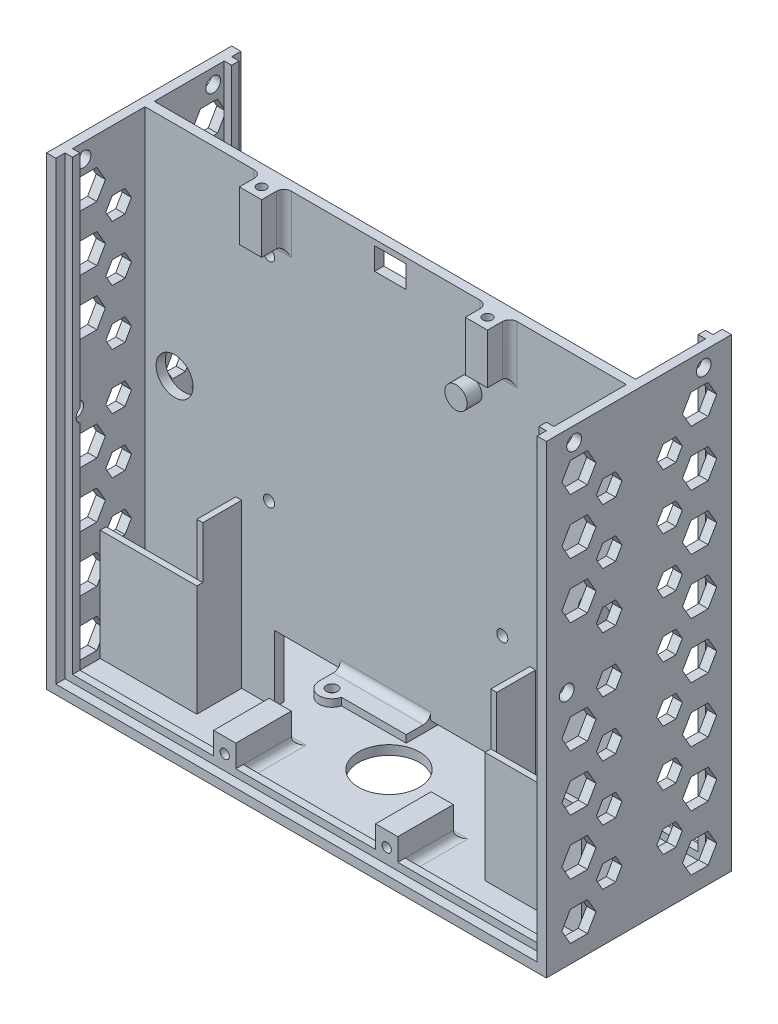
from build123d import *

# Parameters (mm, degrees)
SKETCH1_W                = 130
SKETCH1_H                = 123
SKETCH1_R                = 1.5
SKETCH1_R_2              = 5
SKETCH1_W_2              = 8.5
SKETCH1_H_2              = 6
BOSS_EXTRUDE1_DEPTH      = 2.5
SKETCH1_5_R              = 3
BOSS_EXTRUDE2_DEPTH      = 6.5
SKETCH1_6_W              = 1.6
SKETCH1_6_H              = 44
BOSS_EXTRUDE3_DEPTH      = 13
SKETCH2_W                = 26.1
SKETCH2_H                = 30
BOSS_EXTRUDE4_DEPTH      = 1.6
SKETCH3_W                = 130
SKETCH3_H                = 50
SKETCH3_R                = 8.25
BOSS_EXTRUDE5_DEPTH      = 2.5
SKETCH4_W                = 60
SKETCH4_H                = 18
CUT_EXTRUDE1_DEPTH       = 10
SKETCH6_R                = 1.5
BOSS_EXTRUDE6_DEPTH      = 2
SKETCH7_W                = 50
SKETCH7_H                = 125.5
BOSS_EXTRUDE7_DEPTH      = 2.5
SKETCH8_W                = 50
SKETCH8_H                = 125.5
BOSS_EXTRUDE13_DEPTH     = 2.5
SKETCH12_W               = 2.5
SKETCH12_H               = 7.5
BOSS_EXTRUDE14_DEPTH     = 18
SKETCH13_R               = 1.5
CUT_EXTRUDE2_DEPTH       = 2.5
BOSS_EXTRUDE15_DEPTH     = 2.5
CHAMFER1_SIZE            = 3
CHAMFER1_OF_MIRROR1_SIZE = 3
BOSS_EXTRUDE16_START     = -2.5
SKETCH16_W               = 53
SKETCH16_H               = 2
BOSS_EXTRUDE16_DEPTH     = 2
BOSS_EXTRUDE17_START     = -2.5
BOSS_EXTRUDE17_DEPTH     = 2
SKETCH18_R               = 2
CUT_EXTRUDE3_DEPTH       = 185.557741642
SKETCH19_W               = 6
SKETCH19_H               = 6
SKETCH19_R               = 1.25
BOSS_EXTRUDE18_DEPTH     = 13.5
SKETCH20_W               = 6
SKETCH20_H               = 8
SKETCH20_R               = 1.25
BOSS_EXTRUDE19_DEPTH     = 15
FILLET1_R                = 2
FILLET2_R                = 2
SKETCH21_R               = 2
CUT_EXTRUDE4_DEPTH       = 185.557741709
CUT_EXTRUDE5_DEPTH       = 2.5
CUT_EXTRUDE6_START       = -132.5
CUT_EXTRUDE6_DEPTH       = 2.5


with BuildPart() as part:
    # Sketch1 → Boss-Extrude1 (new body)
    with BuildSketch(Plane.XY):
        with Locations((65, 61.5)):
            Rectangle(SKETCH1_W, SKETCH1_H)
        with Locations((33.523, 105.1)):
            Circle(SKETCH1_R, mode=Mode.SUBTRACT)
        with Locations((33.5, 47.5)):
            Circle(SKETCH1_R, mode=Mode.SUBTRACT)
        with Locations((96.5, 47.5)):
            Circle(SKETCH1_R, mode=Mode.SUBTRACT)
        with Locations((8, 64)):
            Circle(SKETCH1_R_2, mode=Mode.SUBTRACT)
        with Locations((122, 64)):
            Circle(SKETCH1_R_2, mode=Mode.SUBTRACT)
        with Locations((66.25, 118.5)):
            Rectangle(SKETCH1_W_2, SKETCH1_H_2, mode=Mode.SUBTRACT)
    extrude(amount=BOSS_EXTRUDE1_DEPTH)

    # Sketch1_5 → Boss-Extrude2 (add)
    with BuildSketch(Plane.XY):
        with Locations(Location((88, 101, 0), (0, 0, 180))):
            Circle(SKETCH1_5_R)
    extrude(amount=BOSS_EXTRUDE2_DEPTH)

    # Sketch1_6 → Boss-Extrude3 (add)
    with BuildSketch(Plane.XY):
        with Locations((25.3, 22)):
            Rectangle(SKETCH1_6_W, SKETCH1_6_H)
        with Locations((104.7, 22)):
            Rectangle(SKETCH1_6_W, SKETCH1_6_H)
    extrude(amount=BOSS_EXTRUDE3_DEPTH)

    # Sketch2 → Boss-Extrude4 (add)
    with BuildSketch(Plane.XY.offset(13)):
        with Locations((116.95, 15)):
            Rectangle(SKETCH2_W, SKETCH2_H)
        with Locations((13.05, 15)):
            Rectangle(SKETCH2_W, SKETCH2_H)
    extrude(amount=BOSS_EXTRUDE4_DEPTH)

    # Sketch3 → Boss-Extrude5 (add)
    with BuildSketch(Plane.XZ):
        with Locations((65, 1.6)):
            Rectangle(SKETCH3_W, SKETCH3_H)
        with Locations(Location((65, 1.6, 0), (0, 0, 6.262913126))):
            Circle(SKETCH3_R, mode=Mode.SUBTRACT)
    extrude(amount=BOSS_EXTRUDE5_DEPTH)

    # Sketch4 → Cut-Extrude1 (cut)
    with BuildSketch(Plane.XY.offset(2.5)):
        with Locations((65, 9)):
            Rectangle(SKETCH4_W, SKETCH4_H)
    extrude(amount=-CUT_EXTRUDE1_DEPTH, mode=Mode.SUBTRACT)

    # Sketch6 → Boss-Extrude6 (add)
    with BuildSketch(Plane.XZ.offset(-18)):
        with BuildLine():
            Line((77.15, 9.109024603), (59.653800708, 9.109024603))
            ThreePointArc((59.653800708, 9.109024603), (55.892638026, 11.725865762), (52.85, 8.3))
            Line((52.85, 8.3), (52.85, -8.3))
            Line((52.85, -8.3), (77.15, -8.3))
            Line((77.15, -8.3), (77.15, 9.109024603))
        make_face()
        with Locations(Location((56.3, 8.3, 0), (0, 0, 270))):
            Circle(SKETCH6_R, mode=Mode.SUBTRACT)
        with Locations(Location((73.7, -5.1, 0), (0, 0, 270))):
            Circle(SKETCH6_R, mode=Mode.SUBTRACT)
    extrude(amount=BOSS_EXTRUDE6_DEPTH)

    # Sketch7 → Boss-Extrude7 (add)
    with BuildSketch(Plane(origin=(130, 0, 0), x_dir=(0, 0, -1), z_dir=(1, 0, 0))):
        with Locations((-1.6, 60.25)):
            Rectangle(SKETCH7_W, SKETCH7_H)
    extrude(amount=BOSS_EXTRUDE7_DEPTH)

    # Sketch8 → Boss-Extrude13 (add)
    with BuildSketch(Plane.ZY):
        with Locations((1.6, 60.25)):
            Rectangle(SKETCH8_W, SKETCH8_H)
    extrude(amount=BOSS_EXTRUDE13_DEPTH)

    # Sketch12 → Boss-Extrude14 (add)
    with BuildSketch(Plane(origin=(0, 0, 0), x_dir=(-1, 0, 0), z_dir=(0, 0, -1))):
        with Locations((-110.75, 101.15)):
            Rectangle(SKETCH12_W, SKETCH12_H)
        with Locations((-110.75, 63.65)):
            Rectangle(SKETCH12_W, SKETCH12_H)
    boss_extrude14 = extrude(amount=BOSS_EXTRUDE14_DEPTH)

    # Sketch13 → Cut-Extrude2 (cut)
    with BuildSketch(Plane.ZY.offset(-109.5)):
        with Locations((-9, 100.4)):
            Circle(SKETCH13_R)
        with Locations((-9, 64.4)):
            Circle(SKETCH13_R)
    cut_extrude2 = extrude(amount=-CUT_EXTRUDE2_DEPTH, mode=Mode.SUBTRACT)

    # Sketch14 → Boss-Extrude15 (add)
    with BuildSketch(Plane.ZY.offset(-109.5)):
        Polygon((-18, 104.9), (0, 123), (0, 104.9), align=None)
        Polygon((-18, 59.9), (0, 41.8), (0, 59.9), align=None)
    boss_extrude15 = extrude(amount=-BOSS_EXTRUDE15_DEPTH)

    # Chamfer1
    chamfer1_edges = [part.edges().sort_by_distance(p)[0] for p in [
        (112, 110.2, 0),
        (109.5, 110.2, 0),
        (109.5, 54.6, 0),
        (112, 54.6, 0),
    ]]
    chamfer(chamfer1_edges, length=CHAMFER1_SIZE)

    # Mirror1: Boss-Extrude14, Cut-Extrude2, Boss-Extrude15 across plane
    add(boss_extrude14.mirror(Plane(origin=(65, 0, 0), x_dir=(0, 0, 1), z_dir=(1, 0, 0))))
    add(cut_extrude2.mirror(Plane(origin=(65, 0, 0), x_dir=(0, 0, 1), z_dir=(1, 0, 0))), mode=Mode.SUBTRACT)
    add(boss_extrude15.mirror(Plane(origin=(65, 0, 0), x_dir=(0, 0, 1), z_dir=(1, 0, 0))))

    # Chamfer1 of Mirror1
    chamfer1_of_mirror1_edges = [part.edges().sort_by_distance(p)[0] for p in [
        (18, 110.2, 0),
        (20.5, 110.2, 0),
        (20.5, 54.6, 0),
        (18, 54.6, 0),
    ]]
    chamfer(chamfer1_of_mirror1_edges, length=CHAMFER1_OF_MIRROR1_SIZE)

    # Sketch16 → Boss-Extrude16 (add)
    with BuildSketch(Plane(origin=(0, 0, -23.4), x_dir=(-1, 0, 0), z_dir=(0, 0, -1)).offset(BOSS_EXTRUDE16_START)):
        Polygon((-130, 123), (-128, 123), (-128, 2), (-95.5, 2), (-95.5, 0), (-128, 0), (-130, 0), align=None)
        Polygon((0, 2), (0, 0), (-34.5, 0), (-34.5, 2), (-2, 2), (-2, 123), (0, 123), align=None)
        with Locations((-65, 1)):
            Rectangle(SKETCH16_W, SKETCH16_H)
    extrude(amount=-BOSS_EXTRUDE16_DEPTH)

    # Sketch17 → Boss-Extrude17 (add)
    with BuildSketch(Plane.XY.offset(26.6).offset(BOSS_EXTRUDE17_START)):
        Polygon((0, 123), (2, 123), (2, 2), (128, 2), (128, 123), (130, 123), (130, 2), (130, 0), (2, 0), (0, 0), align=None)
    extrude(amount=-BOSS_EXTRUDE17_DEPTH)

    # Sketch18 → Cut-Extrude3 (cut, through all)
    with BuildSketch(Plane.ZY.offset(2.5)):
        with Locations((-15.9, 119)):
            Circle(SKETCH18_R)
        with Locations((19.1, 119)):
            Circle(SKETCH18_R)
    extrude(amount=-CUT_EXTRUDE3_DEPTH, mode=Mode.SUBTRACT)

    # Sketch19 → Boss-Extrude18 (add)
    with BuildSketch(Plane(origin=(0, 123, 0), x_dir=(1, 0, 0), z_dir=(0, 1, 0))):
        with Locations((34.5, -5.5)):
            Rectangle(SKETCH19_W, SKETCH19_H)
        with Locations(Location((34.5, -5.5, 0), (0, 0, 180))):
            Circle(SKETCH19_R, mode=Mode.SUBTRACT)
        with Locations((95.5, -5.5)):
            Rectangle(SKETCH19_W, SKETCH19_H)
        with Locations(Location((95.5, -5.5, 0), (0, 0, 180))):
            Circle(SKETCH19_R, mode=Mode.SUBTRACT)
    extrude(amount=-BOSS_EXTRUDE18_DEPTH)

    # Sketch20 → Boss-Extrude19 (add)
    with BuildSketch(Plane.XY.offset(24.1)):
        with Locations((43.125, 4)):
            Rectangle(SKETCH20_W, SKETCH20_H)
        with Locations((43.125, 4)):
            Circle(SKETCH20_R, mode=Mode.SUBTRACT)
        with Locations((86.875, 4)):
            Rectangle(SKETCH20_W, SKETCH20_H)
        with Locations(Location((86.875, 4, 0), (0, 0, 180))):
            Circle(SKETCH20_R, mode=Mode.SUBTRACT)
    extrude(amount=-BOSS_EXTRUDE19_DEPTH)

    # Fillet1
    fillet1_edges = [part.edges().sort_by_distance(p)[0] for p in [
        (34.5, 109.5, 2.5),
        (31.5, 116.25, 2.5),
        (37.5, 116.25, 2.5),
        (98.5, 116.25, 2.5),
        (95.5, 109.5, 2.5),
        (92.5, 116.25, 2.5),
    ]]
    fillet(fillet1_edges, radius=FILLET1_R)

    # Fillet2
    fillet2_edges = [part.edges().sort_by_distance(p)[0] for p in [
        (65, 18, 2.5),
        (65, 18, 0),
        (43.125, 0, 9.1),
        (46.125, 0, 15.6),
        (40.125, 0, 15.6),
        (86.875, 0, 9.1),
        (89.875, 0, 15.6),
        (83.875, 0, 15.6),
    ]]
    fillet(fillet2_edges, radius=FILLET2_R)

    # Sketch21 → Cut-Extrude4 (cut, through all)
    with BuildSketch(Plane.ZY.offset(2.5)):
        with Locations((21.1, 61.5)):
            Circle(SKETCH21_R)
    extrude(amount=-CUT_EXTRUDE4_DEPTH, mode=Mode.SUBTRACT)

    # Sketch22 → Cut-Extrude5 (cut)
    with BuildSketch(Plane.ZY.offset(2.5)):
        Polygon((-12.47179677, 107), (-10.162395693, 111), (-12.47179677, 115), (-17.090598923, 115), (-19.4, 111), (-17.090598923, 107), align=None)
        Polygon((20.119412552, 107.32687009), (22.428813629, 111.32687009), (20.119412552, 115.32687009), (15.500610398, 115.32687009), (13.191209322, 111.32687009), (15.500610398, 107.32687009), align=None)
        Polygon((20.119412552, 92.32687009), (22.428813629, 96.32687009), (20.119412552, 100.32687009), (15.500610398, 100.32687009), (13.191209322, 96.32687009), (15.500610398, 92.32687009), align=None)
        Polygon((20.119412552, 77.32687009), (22.428813629, 81.32687009), (20.119412552, 85.32687009), (15.500610398, 85.32687009), (13.191209322, 81.32687009), (15.500610398, 77.32687009), align=None)
        Polygon((20.119412552, 47.32687009), (22.428813629, 51.32687009), (20.119412552, 55.32687009), (15.500610398, 55.32687009), (13.191209322, 51.32687009), (15.500610398, 47.32687009), align=None)
        Polygon((20.119412552, 32.32687009), (22.428813629, 36.32687009), (20.119412552, 40.32687009), (15.500610398, 40.32687009), (13.191209322, 36.32687009), (15.500610398, 32.32687009), align=None)
        Polygon((20.119412552, 17.32687009), (22.428813629, 21.32687009), (20.119412552, 25.32687009), (15.500610398, 25.32687009), (13.191209322, 21.32687009), (15.500610398, 17.32687009), align=None)
        Polygon((20.119412552, 2.32687009), (22.428813629, 6.32687009), (20.119412552, 10.32687009), (15.500610398, 10.32687009), (13.191209322, 6.32687009), (15.500610398, 2.32687009), align=None)
        Polygon((-12.47179677, 92), (-10.162395693, 96), (-12.47179677, 100), (-17.090598923, 100), (-19.4, 96), (-17.090598923, 92), align=None)
        Polygon((-12.47179677, 77), (-10.162395693, 81), (-12.47179677, 85), (-17.090598923, 85), (-19.4, 81), (-17.090598923, 77), align=None)
        Polygon((-12.47179677, 62), (-10.162395693, 66), (-12.47179677, 70), (-17.090598923, 70), (-19.4, 66), (-17.090598923, 62), align=None)
        Polygon((-12.47179677, 47), (-10.162395693, 51), (-12.47179677, 55), (-17.090598923, 55), (-19.4, 51), (-17.090598923, 47), align=None)
        Polygon((-12.47179677, 32), (-10.162395693, 36), (-12.47179677, 40), (-17.090598923, 40), (-19.4, 36), (-17.090598923, 32), align=None)
        Polygon((-12.47179677, 17), (-10.162395693, 21), (-12.47179677, 25), (-17.090598923, 25), (-19.4, 21), (-17.090598923, 17), align=None)
        Polygon((-12.47179677, 2), (-10.162395693, 6), (-12.47179677, 10), (-17.090598923, 10), (-19.4, 6), (-17.090598923, 2), align=None)
        Polygon((13.098833486, 103.608547264), (11.366782678, 106.608547264), (7.902681063, 106.608547264), (6.170630255, 103.608547264), (7.902681063, 100.608547264), (11.366782678, 100.608547264), align=None)
        Polygon((-3.201166514, 103.608547264), (-4.933217322, 106.608547264), (-8.397318937, 106.608547264), (-10.129369745, 103.608547264), (-8.397318937, 100.608547264), (-4.933217322, 100.608547264), align=None)
        Polygon((13.098833486, 88.608547264), (11.366782678, 91.608547264), (7.902681063, 91.608547264), (6.170630255, 88.608547264), (7.902681063, 85.608547264), (11.366782678, 85.608547264), align=None)
        Polygon((13.098833486, 73.608547264), (11.366782678, 76.608547264), (7.902681063, 76.608547264), (6.170630255, 73.608547264), (7.902681063, 70.608547264), (11.366782678, 70.608547264), align=None)
        Polygon((13.098833486, 58.608547264), (11.366782678, 61.608547264), (7.902681063, 61.608547264), (6.170630255, 58.608547264), (7.902681063, 55.608547264), (11.366782678, 55.608547264), align=None)
        Polygon((13.098833486, 43.608547264), (11.366782678, 46.608547264), (7.902681063, 46.608547264), (6.170630255, 43.608547264), (7.902681063, 40.608547264), (11.366782678, 40.608547264), align=None)
        Polygon((13.098833486, 28.608547264), (11.366782678, 31.608547264), (7.902681063, 31.608547264), (6.170630255, 28.608547264), (7.902681063, 25.608547264), (11.366782678, 25.608547264), align=None)
        Polygon((13.098833486, 13.608547264), (11.366782678, 16.608547264), (7.902681063, 16.608547264), (6.170630255, 13.608547264), (7.902681063, 10.608547264), (11.366782678, 10.608547264), align=None)
        Polygon((-3.201166514, 88.608547264), (-4.933217322, 91.608547264), (-8.397318937, 91.608547264), (-10.129369745, 88.608547264), (-8.397318937, 85.608547264), (-4.933217322, 85.608547264), align=None)
        Polygon((-3.201166514, 73.608547264), (-4.933217322, 76.608547264), (-8.397318937, 76.608547264), (-10.129369745, 73.608547264), (-8.397318937, 70.608547264), (-4.933217322, 70.608547264), align=None)
        Polygon((-3.201166514, 58.608547264), (-4.933217322, 61.608547264), (-8.397318937, 61.608547264), (-10.129369745, 58.608547264), (-8.397318937, 55.608547264), (-4.933217322, 55.608547264), align=None)
        Polygon((-3.201166514, 43.608547264), (-4.933217322, 46.608547264), (-8.397318937, 46.608547264), (-10.129369745, 43.608547264), (-8.397318937, 40.608547264), (-4.933217322, 40.608547264), align=None)
        Polygon((-3.201166514, 28.608547264), (-4.933217322, 31.608547264), (-8.397318937, 31.608547264), (-10.129369745, 28.608547264), (-8.397318937, 25.608547264), (-4.933217322, 25.608547264), align=None)
        Polygon((-3.201166514, 13.608547264), (-4.933217322, 16.608547264), (-8.397318937, 16.608547264), (-10.129369745, 13.608547264), (-8.397318937, 10.608547264), (-4.933217322, 10.608547264), align=None)
    extrude(amount=-CUT_EXTRUDE5_DEPTH, mode=Mode.SUBTRACT)

    # Sketch22_2 → Cut-Extrude6 (cut)
    with BuildSketch(Plane.ZY.offset(2.5).offset(CUT_EXTRUDE6_START)):
        Polygon((-12.47179677, 107), (-10.162395693, 111), (-12.47179677, 115), (-17.090598923, 115), (-19.4, 111), (-17.090598923, 107), align=None)
        Polygon((20.119412552, 107.32687009), (22.428813629, 111.32687009), (20.119412552, 115.32687009), (15.500610398, 115.32687009), (13.191209322, 111.32687009), (15.500610398, 107.32687009), align=None)
        Polygon((20.119412552, 92.32687009), (22.428813629, 96.32687009), (20.119412552, 100.32687009), (15.500610398, 100.32687009), (13.191209322, 96.32687009), (15.500610398, 92.32687009), align=None)
        Polygon((20.119412552, 77.32687009), (22.428813629, 81.32687009), (20.119412552, 85.32687009), (15.500610398, 85.32687009), (13.191209322, 81.32687009), (15.500610398, 77.32687009), align=None)
        Polygon((20.119412552, 47.32687009), (22.428813629, 51.32687009), (20.119412552, 55.32687009), (15.500610398, 55.32687009), (13.191209322, 51.32687009), (15.500610398, 47.32687009), align=None)
        Polygon((20.119412552, 32.32687009), (22.428813629, 36.32687009), (20.119412552, 40.32687009), (15.500610398, 40.32687009), (13.191209322, 36.32687009), (15.500610398, 32.32687009), align=None)
        Polygon((20.119412552, 17.32687009), (22.428813629, 21.32687009), (20.119412552, 25.32687009), (15.500610398, 25.32687009), (13.191209322, 21.32687009), (15.500610398, 17.32687009), align=None)
        Polygon((20.119412552, 2.32687009), (22.428813629, 6.32687009), (20.119412552, 10.32687009), (15.500610398, 10.32687009), (13.191209322, 6.32687009), (15.500610398, 2.32687009), align=None)
        Polygon((-12.47179677, 92), (-10.162395693, 96), (-12.47179677, 100), (-17.090598923, 100), (-19.4, 96), (-17.090598923, 92), align=None)
        Polygon((-12.47179677, 77), (-10.162395693, 81), (-12.47179677, 85), (-17.090598923, 85), (-19.4, 81), (-17.090598923, 77), align=None)
        Polygon((-12.47179677, 62), (-10.162395693, 66), (-12.47179677, 70), (-17.090598923, 70), (-19.4, 66), (-17.090598923, 62), align=None)
        Polygon((-12.47179677, 47), (-10.162395693, 51), (-12.47179677, 55), (-17.090598923, 55), (-19.4, 51), (-17.090598923, 47), align=None)
        Polygon((-12.47179677, 32), (-10.162395693, 36), (-12.47179677, 40), (-17.090598923, 40), (-19.4, 36), (-17.090598923, 32), align=None)
        Polygon((-12.47179677, 17), (-10.162395693, 21), (-12.47179677, 25), (-17.090598923, 25), (-19.4, 21), (-17.090598923, 17), align=None)
        Polygon((-12.47179677, 2), (-10.162395693, 6), (-12.47179677, 10), (-17.090598923, 10), (-19.4, 6), (-17.090598923, 2), align=None)
        Polygon((13.098833486, 103.608547264), (11.366782678, 106.608547264), (7.902681063, 106.608547264), (6.170630255, 103.608547264), (7.902681063, 100.608547264), (11.366782678, 100.608547264), align=None)
        Polygon((-3.201166514, 103.608547264), (-4.933217322, 106.608547264), (-8.397318937, 106.608547264), (-10.129369745, 103.608547264), (-8.397318937, 100.608547264), (-4.933217322, 100.608547264), align=None)
        Polygon((13.098833486, 88.608547264), (11.366782678, 91.608547264), (7.902681063, 91.608547264), (6.170630255, 88.608547264), (7.902681063, 85.608547264), (11.366782678, 85.608547264), align=None)
        Polygon((13.098833486, 73.608547264), (11.366782678, 76.608547264), (7.902681063, 76.608547264), (6.170630255, 73.608547264), (7.902681063, 70.608547264), (11.366782678, 70.608547264), align=None)
        Polygon((13.098833486, 58.608547264), (11.366782678, 61.608547264), (7.902681063, 61.608547264), (6.170630255, 58.608547264), (7.902681063, 55.608547264), (11.366782678, 55.608547264), align=None)
        Polygon((13.098833486, 43.608547264), (11.366782678, 46.608547264), (7.902681063, 46.608547264), (6.170630255, 43.608547264), (7.902681063, 40.608547264), (11.366782678, 40.608547264), align=None)
        Polygon((13.098833486, 28.608547264), (11.366782678, 31.608547264), (7.902681063, 31.608547264), (6.170630255, 28.608547264), (7.902681063, 25.608547264), (11.366782678, 25.608547264), align=None)
        Polygon((13.098833486, 13.608547264), (11.366782678, 16.608547264), (7.902681063, 16.608547264), (6.170630255, 13.608547264), (7.902681063, 10.608547264), (11.366782678, 10.608547264), align=None)
        Polygon((-3.201166514, 88.608547264), (-4.933217322, 91.608547264), (-8.397318937, 91.608547264), (-10.129369745, 88.608547264), (-8.397318937, 85.608547264), (-4.933217322, 85.608547264), align=None)
        Polygon((-3.201166514, 73.608547264), (-4.933217322, 76.608547264), (-8.397318937, 76.608547264), (-10.129369745, 73.608547264), (-8.397318937, 70.608547264), (-4.933217322, 70.608547264), align=None)
        Polygon((-3.201166514, 58.608547264), (-4.933217322, 61.608547264), (-8.397318937, 61.608547264), (-10.129369745, 58.608547264), (-8.397318937, 55.608547264), (-4.933217322, 55.608547264), align=None)
        Polygon((-3.201166514, 43.608547264), (-4.933217322, 46.608547264), (-8.397318937, 46.608547264), (-10.129369745, 43.608547264), (-8.397318937, 40.608547264), (-4.933217322, 40.608547264), align=None)
        Polygon((-3.201166514, 28.608547264), (-4.933217322, 31.608547264), (-8.397318937, 31.608547264), (-10.129369745, 28.608547264), (-8.397318937, 25.608547264), (-4.933217322, 25.608547264), align=None)
        Polygon((-3.201166514, 13.608547264), (-4.933217322, 16.608547264), (-8.397318937, 16.608547264), (-10.129369745, 13.608547264), (-8.397318937, 10.608547264), (-4.933217322, 10.608547264), align=None)
    extrude(amount=-CUT_EXTRUDE6_DEPTH, mode=Mode.SUBTRACT)


solid = part.part
